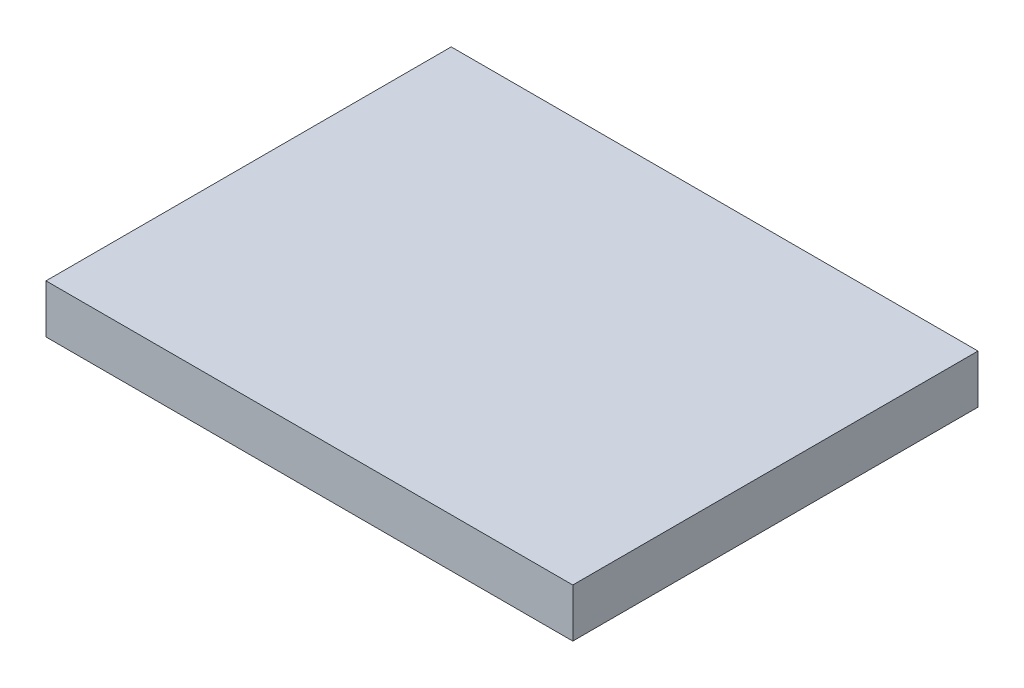
from build123d import *

# Parameters (mm, degrees)
SKETCH1_W           = 130
SKETCH1_H           = 100
BOSS_EXTRUDE1_DEPTH = 12


with BuildPart() as part:
    # Sketch1 → Boss-Extrude1 (new body)
    with BuildSketch(Plane(origin=(0, 0, 0), x_dir=(1, 0, 0), z_dir=(0, 1, 0))):
        with Locations((65, 50)):
            Rectangle(SKETCH1_W, SKETCH1_H)
    extrude(amount=BOSS_EXTRUDE1_DEPTH)


solid = part.part
